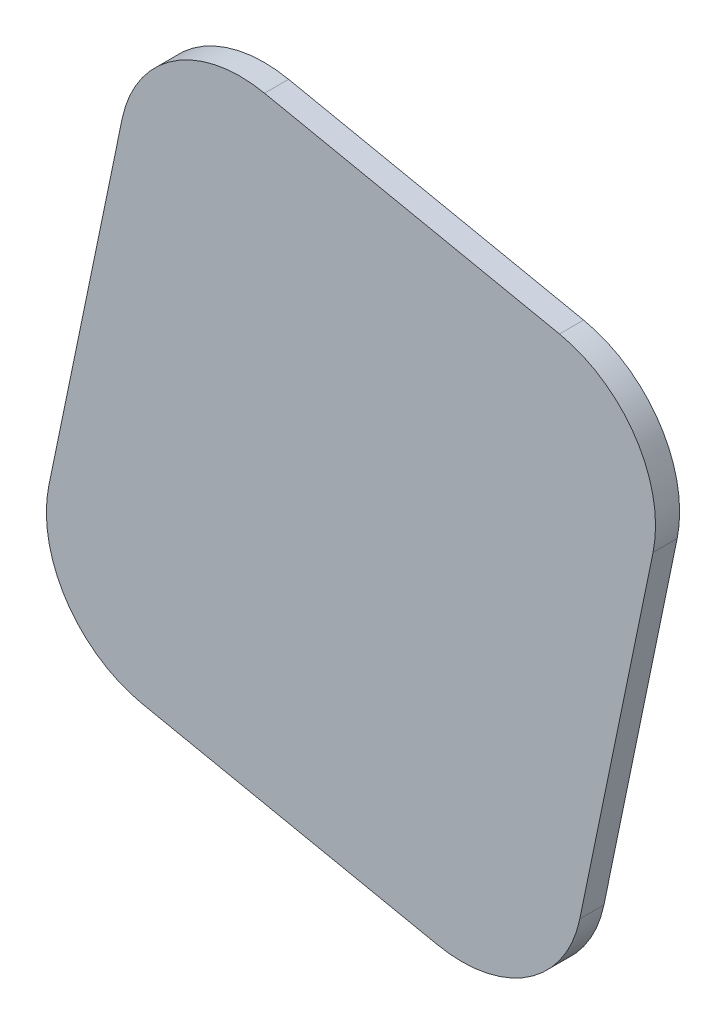
from build123d import *

# Parameters (mm, degrees)
BOSS_EXTRU_1_DEPTH = 2
CONG_1_R           = 10


with BuildPart() as part:
    # Esquisse1 → Boss.-Extru.1 (new body)
    with BuildSketch(Plane.XY):
        Polygon((-99.209210776, 80.763658909), (-55.142491898, 71.646406727), (-65.2727721, 22.683385752), (-109.339490978, 31.800637933), align=None)
    extrude(amount=BOSS_EXTRU_1_DEPTH)

    # Congé1
    cong_1_edges = [part.edges().sort_by_distance(p)[0] for p in [
        (-99.209210776, 80.763658909, 1),
        (-55.142491898, 71.646406727, 1),
        (-65.2727721, 22.683385752, 1),
        (-109.339490978, 31.800637933, 1),
    ]]
    fillet(cong_1_edges, radius=CONG_1_R)


solid = part.part
